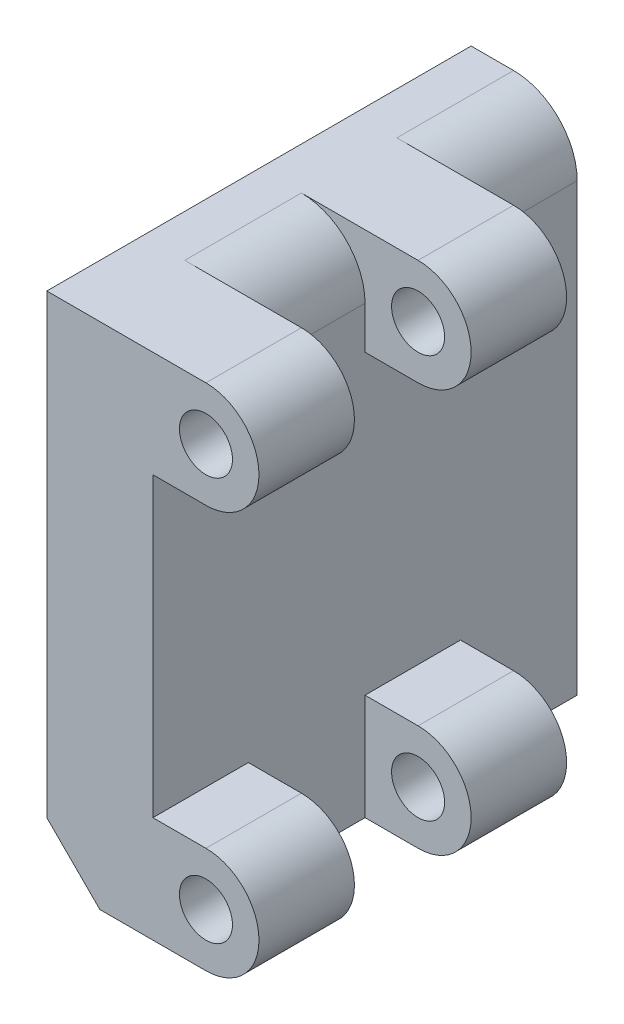
from build123d import *

# Parameters (mm, degrees)
SKETCH1_W           = 40
SKETCH1_H           = 48
BOSS_EXTRUDE1_DEPTH = 10
SKETCH6_R           = 2.5
BOSS_EXTRUDE2_DEPTH = 9
LPATTERN1_COUNT     = 2
LPATTERN1_PITCH     = 20
FILLET1_R           = 6
CHAMFER2_SIZE       = 5


with BuildPart() as part:
    # Sketch1 → Boss-Extrude1 (new body)
    with BuildSketch(Plane(origin=(0, 0, 0), x_dir=(0, 0, -1), z_dir=(1, 0, 0))):
        Rectangle(SKETCH1_W, SKETCH1_H)
    extrude(amount=BOSS_EXTRUDE1_DEPTH)

    # Sketch6 → Boss-Extrude2 (add)
    with BuildSketch(Plane.XY.offset(20)):
        with BuildLine():
            Line((5, 24), (15, 24))
            ThreePointArc((15, 24), (20, 19), (15, 14))
            Line((15, 14), (5, 14))
            ThreePointArc((5, 14), (0, 19), (5, 24))
        make_face()
        with Locations((15, 19)):
            Circle(SKETCH6_R, mode=Mode.SUBTRACT)
        with BuildLine():
            Line((5, -14), (15, -14))
            ThreePointArc((15, -14), (20, -19), (15, -24))
            Line((15, -24), (5, -24))
            ThreePointArc((5, -24), (0, -19), (5, -14))
        make_face()
        with Locations((15, -19)):
            Circle(SKETCH6_R, mode=Mode.SUBTRACT)
    boss_extrude2 = extrude(amount=-BOSS_EXTRUDE2_DEPTH)

    # LPattern1: Boss-Extrude2 ×2
    with Locations(*[(0, 0, -i * LPATTERN1_PITCH) for i in range(1, LPATTERN1_COUNT)]):
        add(boss_extrude2)

    # Fillet1
    fillet1_edges = [part.edges().sort_by_distance(p)[0] for p in [
        (10, 24, 5.5),
        (10, 24, -14.5),
    ]]
    fillet(fillet1_edges, radius=FILLET1_R)

    # Chamfer2
    chamfer2_edges = [part.edges().sort_by_distance(p)[0] for p in [
        (0, -24, 0),
    ]]
    chamfer(chamfer2_edges, length=CHAMFER2_SIZE)


solid = part.part
